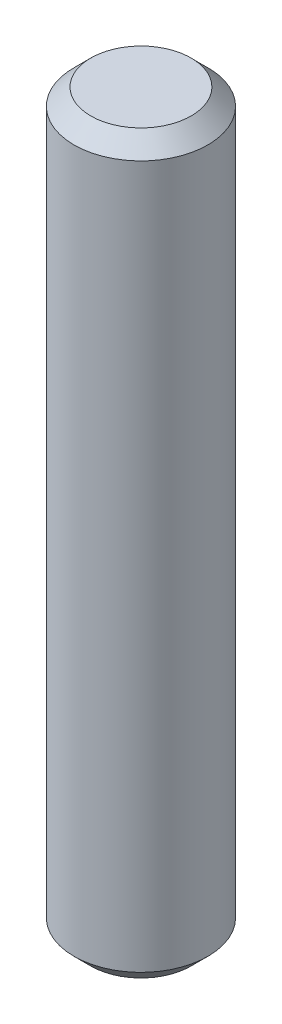
from build123d import *

# Parameters (mm, degrees)
SKETCH1_R           = 2
BOSS_EXTRUDE1_DEPTH = 22
CHAMFER1_SIZE       = 0.5


with BuildPart() as part:
    # Sketch1 → Boss-Extrude1 (new body)
    with BuildSketch(Plane(origin=(0, 0, 0), x_dir=(1, 0, 0), z_dir=(0, 1, 0))):
        Circle(SKETCH1_R)
    extrude(amount=BOSS_EXTRUDE1_DEPTH)

    # Chamfer1
    chamfer1_edges = [part.edges().sort_by_distance(p)[0] for p in [
        (-2, 0, 0),
        (-2, 22, 0),
    ]]
    chamfer(chamfer1_edges, length=CHAMFER1_SIZE)


solid = part.part
